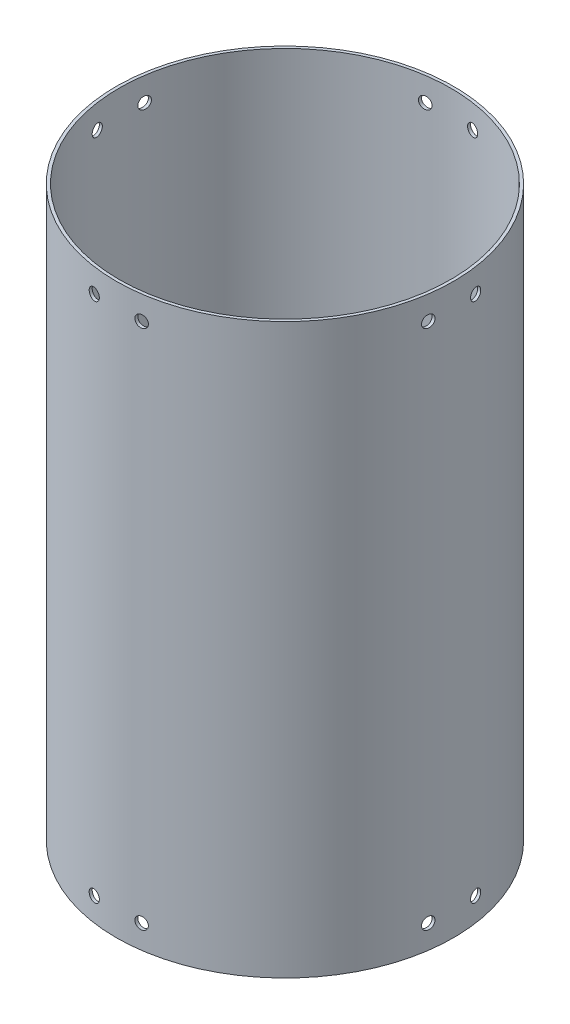
from build123d import *

# Parameters (mm, degrees)
SKETCH1_R           = 90.4875
SKETCH1_R_2         = 88.9
BOSS_EXTRUDE1_DEPTH = 304.8
SKETCH2_R           = 3.175
CUT_EXTRUDE1_DEPTH  = 25.4
CIRPATTERN1_COUNT   = 4


with BuildPart() as part:
    # Sketch1 → Boss-Extrude1 (new body)
    with BuildSketch(Plane(origin=(0, 0, 0), x_dir=(1, 0, 0), z_dir=(0, 1, 0))):
        Circle(SKETCH1_R)
        Circle(SKETCH1_R_2, mode=Mode.SUBTRACT)
    extrude(amount=BOSS_EXTRUDE1_DEPTH)

    # Sketch2 → Cut-Extrude1 (cut)
    with BuildSketch(Plane(origin=(0, 0, -90.4875), x_dir=(-1, 0, 0), z_dir=(0, 0, -1))):
        with Locations((-12.7, 292.1)):
            Circle(SKETCH2_R)
        with Locations((12.7, 292.1)):
            Circle(SKETCH2_R)
        with Locations((-12.7, 12.7)):
            Circle(SKETCH2_R)
        with Locations((12.7, 12.7)):
            Circle(SKETCH2_R)
    cut_extrude1 = extrude(amount=-CUT_EXTRUDE1_DEPTH, mode=Mode.SUBTRACT)

    # CirPattern1: Cut-Extrude1 ×4 about axis
    cirpattern1_axis = Axis((0, 304.8, 0), (0, 1, 0))
    for i in range(1, CIRPATTERN1_COUNT):
        add(cut_extrude1.rotate(cirpattern1_axis, i * 360 / CIRPATTERN1_COUNT), mode=Mode.SUBTRACT)


solid = part.part
